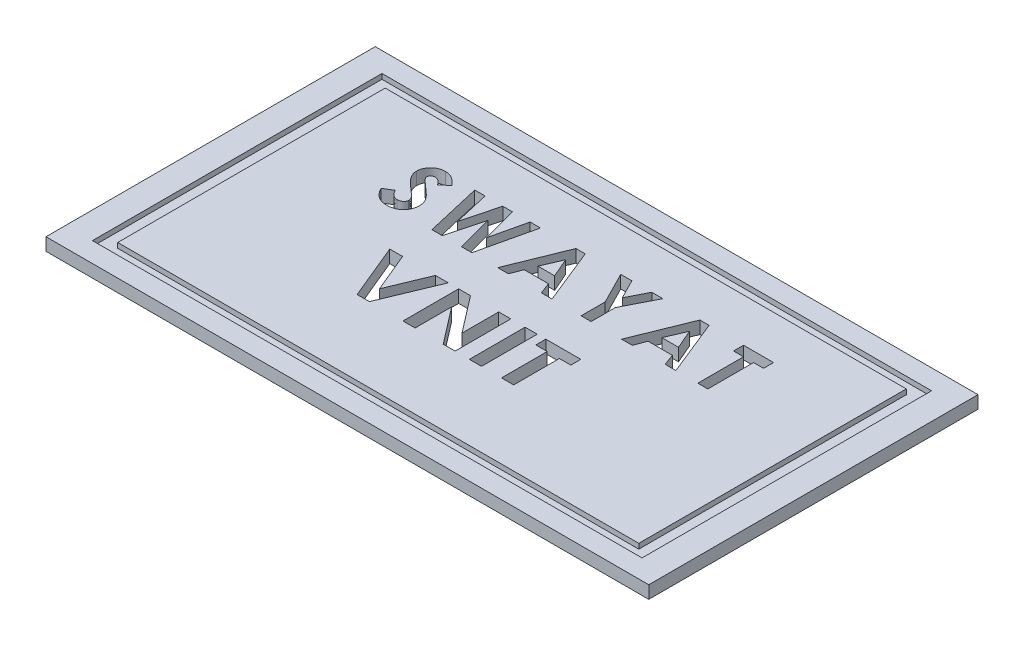
from build123d import *

# Parameters (mm, degrees)
SKETCH4_W           = 119
SKETCH4_H           = 65
BOSS_EXTRUDE2_DEPTH = 2.5
SKETCH5_W           = 2.397435898
SKETCH5_H           = 11
CUT_EXTRUDE1_DEPTH  = 2.5
SKETCH6_W           = 108.50389602
SKETCH6_H           = 57.15903792
SKETCH6_W_2         = 102.871220824
SKETCH6_H_2         = 52.803857444
CUT_EXTRUDE2_DEPTH  = 1


with BuildPart() as part:
    # Sketch4 → Boss-Extrude2 (new body)
    with BuildSketch(Plane(origin=(0, 0, 0), x_dir=(1, 0, 0), z_dir=(0, 1, 0))):
        Rectangle(SKETCH4_W, SKETCH4_H)
    extrude(amount=BOSS_EXTRUDE2_DEPTH)

    # Sketch5 → Cut-Extrude1 (cut)
    with BuildSketch(Plane(origin=(0, 2.5, 0), x_dir=(1, 0, 0), z_dir=(0, 1, 0))):
        with BuildLine():
            Line((-28.220512821, 16.333954193), (-29.696875, 14.983192975))
            add(Edge.make_bspline(
                [(-29.696875, 14.983192975), (-29.760116025, 15.072401015), (-29.881529975, 15.243668013), (-30.078329322, 15.47299856), (-30.27424002, 15.668634583), (-30.471077062, 15.829758805), (-30.670585136, 15.955392277), (-30.872417925, 16.044342163), (-31.075431182, 16.10088845), (-31.211824753, 16.107929823), (-31.27900641, 16.111398103)],
                knots=[0, 0, 0, 0, 0.000327904, 0.000629529, 0.000905322, 0.001157575, 0.001391149, 0.001610187, 0.001817564, 0.002018858, 0.002018858, 0.002018858, 0.002018858], degree=3))
            add(Edge.make_bspline(
                [(-31.27900641, 16.111398103), (-31.341671533, 16.109200441), (-31.46266142, 16.104957335), (-31.63514148, 16.06278117), (-31.788271734, 15.989991302), (-31.921902733, 15.894812427), (-32.0277582, 15.780143949), (-32.112275582, 15.659886198), (-32.15986597, 15.527148839), (-32.166129801, 15.435979466), (-32.169230769, 15.390845218)],
                knots=[0, 0, 0, 0, 0.000187766, 0.000362526, 0.000528128, 0.000693862, 0.000851302, 0.000994311, 0.001132309, 0.001267606, 0.001267606, 0.001267606, 0.001267606], degree=3))
            add(Edge.make_bspline(
                [(-32.169230769, 15.390845218), (-32.16728755, 15.345060115), (-32.163374176, 15.252855278), (-32.125576309, 15.117717608), (-32.068604132, 14.985672372), (-32.01416489, 14.905290154), (-31.986338141, 14.86420259)],
                knots=[0, 0, 0, 0, 0.000137062, 0.000276024, 0.000418096, 0.00056665, 0.00056665, 0.00056665, 0.00056665], degree=3))
            add(Edge.make_bspline(
                [(-31.986338141, 14.86420259), (-31.961040616, 14.832265656), (-31.902809053, 14.758751052), (-31.79177339, 14.642315379), (-31.652335917, 14.499671488), (-31.479130786, 14.335724484), (-31.279348218, 14.144578192), (-31.043728034, 13.933746645), (-30.779052409, 13.696700635), (-30.590927108, 13.531630378), (-30.492347756, 13.445132077)],
                knots=[0, 0, 0, 0, 0.000122172, 0.000281223, 0.000482227, 0.000720667, 0.000996565, 0.001311693, 0.001669078, 0.002062517, 0.002062517, 0.002062517, 0.002062517], degree=3))
            add(Edge.make_bspline(
                [(-30.492347756, 13.445132077), (-30.399816855, 13.365051249), (-30.224212428, 13.213074475), (-29.9743622, 12.997367846), (-29.754785462, 12.803301851), (-29.562283482, 12.633789006), (-29.399774401, 12.487050733), (-29.266575032, 12.362385625), (-29.161058569, 12.262220682), (-29.101078639, 12.201720996), (-29.075480769, 12.175901308)],
                knots=[0, 0, 0, 0, 0.000367117, 0.000696712, 0.000990236, 0.001246243, 0.00146621, 0.00164706, 0.001793557, 0.001902626, 0.001902626, 0.001902626, 0.001902626], degree=3))
            add(Edge.make_bspline(
                [(-29.075480769, 12.175901308), (-28.978367789, 12.070804265), (-28.791682538, 11.868770841), (-28.549057521, 11.555682571), (-28.349369285, 11.25004458), (-28.194886678, 10.946105793), (-28.078215201, 10.639480977), (-27.995960263, 10.322650177), (-27.946697234, 9.992302709), (-27.941227887, 9.76688089), (-27.938461538, 9.652864449)],
                knots=[0, 0, 0, 0, 0.000429122, 0.000824923, 0.001186765, 0.001522808, 0.001845705, 0.002169053, 0.002503118, 0.002845013, 0.002845013, 0.002845013, 0.002845013], degree=3))
            add(Edge.make_bspline(
                [(-27.938461538, 9.652864449), (-27.940430555, 9.54176941), (-27.944293838, 9.323796809), (-27.991611651, 9.004826376), (-28.059084074, 8.699557828), (-28.163408278, 8.411312919), (-28.290557999, 8.135360196), (-28.449958539, 7.875998124), (-28.637152617, 7.630601855), (-28.851705771, 7.403558146), (-29.089027037, 7.197531717), (-29.34357665, 7.014122124), (-29.617843723, 6.862694143), (-29.909484962, 6.738004002), (-30.218344258, 6.641965988), (-30.544053667, 6.570984945), (-30.887111383, 6.528383241), (-31.121699192, 6.523929739), (-31.241546474, 6.521654513)],
                knots=[0, 0, 0, 0, 0.000332995, 0.000653348, 0.000965503, 0.001269366, 0.001571016, 0.001875613, 0.002180592, 0.002495473, 0.00281097, 0.003122198, 0.003434889, 0.00374882, 0.004072191, 0.004403695, 0.004747798, 0.005107216, 0.005107216, 0.005107216, 0.005107216], degree=3))
            add(Edge.make_bspline(
                [(-31.241546474, 6.521654513), (-31.33562557, 6.523323539), (-31.521956134, 6.526629167), (-31.796579216, 6.553616871), (-32.061758846, 6.597172154), (-32.317196323, 6.659599885), (-32.564042437, 6.738704288), (-32.802307328, 6.835327285), (-33.030346172, 6.950966497), (-33.24988442, 7.083243923), (-33.459854845, 7.236835438), (-33.66291244, 7.408600915), (-33.857040245, 7.601182182), (-34.043170617, 7.814123794), (-34.22011264, 8.048028749), (-34.393658263, 8.299639488), (-34.556094596, 8.573625565), (-34.656438744, 8.765829014), (-34.707692308, 8.86400227)],
                knots=[0, 0, 0, 0, 0.000282189, 0.000558896, 0.000826966, 0.001087775, 0.001347005, 0.001603978, 0.001858226, 0.002113312, 0.002372036, 0.002637814, 0.002910491, 0.003191577, 0.003485539, 0.003789913, 0.004108107, 0.004440321, 0.004440321, 0.004440321, 0.004440321], degree=3))
            Line((-34.707692308, 8.86400227), (-32.971314103, 9.906269898))
            add(Edge.make_bspline(
                [(-32.971314103, 9.906269898), (-32.907203555, 9.794830426), (-32.784298156, 9.581191434), (-32.576023467, 9.294140371), (-32.36265668, 9.048328652), (-32.139264948, 8.848101013), (-31.90856463, 8.690780155), (-31.669441389, 8.578347755), (-31.421727223, 8.508752227), (-31.252995586, 8.500253006), (-31.168830128, 8.496013488)],
                knots=[0, 0, 0, 0, 0.00038546, 0.000738959, 0.001062127, 0.001360222, 0.001636464, 0.001896713, 0.00215008, 0.002402247, 0.002402247, 0.002402247, 0.002402247], degree=3))
            add(Edge.make_bspline(
                [(-31.168830128, 8.496013488), (-31.083221808, 8.499475708), (-30.917129199, 8.50619292), (-30.680053253, 8.568237782), (-30.46269305, 8.665652768), (-30.274808495, 8.804650519), (-30.115719701, 8.96507505), (-29.998303038, 9.143554676), (-29.924541099, 9.336665323), (-29.916742674, 9.470812681), (-29.912820513, 9.538281116)],
                knots=[0, 0, 0, 0, 0.000256377, 0.000497409, 0.000730108, 0.0009668, 0.001194308, 0.001404557, 0.001603924, 0.001805652, 0.001805652, 0.001805652, 0.001805652], degree=3))
            add(Edge.make_bspline(
                [(-29.912820513, 9.538281116), (-29.916442468, 9.601049515), (-29.923800123, 9.728557508), (-29.977994345, 9.918141391), (-30.062716442, 10.107639055), (-30.162948658, 10.263070165), (-30.264947489, 10.393208421), (-30.362481377, 10.505967332), (-30.481251851, 10.630546189), (-30.620957763, 10.767101702), (-30.779753233, 10.916836004), (-30.957772024, 11.079734431), (-31.157052642, 11.254362045), (-31.297904575, 11.37331665), (-31.371554487, 11.435516693)],
                knots=[0, 0, 0, 0, 0.000188127, 0.000382163, 0.000587328, 0.000809228, 0.000934848, 0.001083272, 0.001256287, 0.001451059, 0.001669286, 0.001911042, 0.002174923, 0.002464123, 0.002464123, 0.002464123, 0.002464123], degree=3))
            add(Edge.make_bspline(
                [(-31.371554487, 11.435516693), (-31.511565902, 11.553979775), (-31.780290184, 11.781346287), (-32.160031689, 12.117159467), (-32.502212786, 12.431007654), (-32.803878033, 12.726770698), (-33.068871111, 12.99898654), (-33.295397371, 13.249866222), (-33.480968321, 13.481344938), (-33.676241731, 13.755515986), (-33.861790512, 14.089612248), (-34.022157314, 14.49156878), (-34.126196527, 14.893474311), (-34.137852673, 15.163291547), (-34.143589744, 15.296093616)],
                knots=[0, 0, 0, 0, 0.000550193, 0.001055988, 0.001520686, 0.001942965, 0.002323199, 0.002660274, 0.002956572, 0.003212731, 0.003669462, 0.004098697, 0.004509151, 0.004906984, 0.004906984, 0.004906984, 0.004906984], degree=3))
            add(Edge.make_bspline(
                [(-34.143589744, 15.296093616), (-34.141203704, 15.390269715), (-34.136502949, 15.575806746), (-34.094571492, 15.848611917), (-34.031903331, 16.111845984), (-33.940891171, 16.364548551), (-33.822768376, 16.606403097), (-33.679312829, 16.838593602), (-33.508296939, 17.058983037), (-33.315573576, 17.267425299), (-33.103241772, 17.457917806), (-32.876338257, 17.626046531), (-32.636147323, 17.768050497), (-32.384138338, 17.885853097), (-32.118749706, 17.976023505), (-31.841936534, 18.039940784), (-31.553301784, 18.077956744), (-31.356978657, 18.083124572), (-31.256971154, 18.085757077)],
                knots=[0, 0, 0, 0, 0.000282361, 0.000556281, 0.000826175, 0.001093129, 0.001360202, 0.001632317, 0.001910424, 0.00219577, 0.002482889, 0.002764949, 0.003041577, 0.0033186, 0.003598031, 0.003880787, 0.004169684, 0.004469655, 0.004469655, 0.004469655, 0.004469655], degree=3))
            add(Edge.make_bspline(
                [(-31.256971154, 18.085757077), (-31.12736638, 18.081015858), (-30.869179887, 18.071570846), (-30.48744371, 17.997713939), (-30.114579773, 17.881566172), (-29.814119024, 17.74144667), (-29.575048015, 17.605712842), (-29.391822419, 17.480746232), (-29.205380513, 17.337590263), (-29.014218758, 17.175793813), (-28.821889235, 16.992308425), (-28.622923098, 16.791502113), (-28.420031501, 16.571639441), (-28.288184133, 16.414570567), (-28.220512821, 16.333954193)],
                knots=[0, 0, 0, 0, 0.000388577, 0.000774087, 0.001162264, 0.001557636, 0.001765901, 0.001986529, 0.002222317, 0.002470886, 0.002737439, 0.003019465, 0.003318885, 0.003634613, 0.003634613, 0.003634613, 0.003634613], degree=3))
        make_face()
        Polygon((-25.16025641, 17.803705795), (-23.121995192, 17.803705795), (-21.493589744, 10.781069577), (-19.627203526, 17.803705795), (-17.707932692, 17.803705795), (-15.852564103, 10.781069577), (-14.228565705, 17.803705795), (-12.185897436, 17.803705795), (-14.730969551, 6.803705795), (-16.793469551, 6.803705795), (-18.673076923, 13.914483039), (-20.563701923, 6.803705795), (-22.610777244, 6.803705795), align=None)
        Polygon((-5.174719551, 17.803705795), (-3.343589744, 17.803705795), (1.098717949, 6.803705795), (-1.01005609, 6.803705795), (-1.865024038, 9.060116052), (-6.657692308, 9.060116052), (-7.512660256, 6.803705795), (-9.619230769, 6.803705795), align=None)
        Polygon((-4.26025641, 14.853184962), (-5.90849359, 11.034475026), (-2.612019231, 11.034475026), align=None, mode=Mode.SUBTRACT)
        Polygon((3.665384615, 17.803705795), (5.862299679, 17.803705795), (7.825641026, 13.945332398), (9.788982372, 17.803705795), (11.985897436, 17.803705795), (8.812820513, 11.567728231), (8.812820513, 6.803705795), (6.838461538, 6.803705795), (6.838461538, 11.567728231), align=None)
        Polygon((19.279126603, 17.803705795), (21.11025641, 17.803705795), (25.552564103, 6.803705795), (23.443790064, 6.803705795), (22.588822115, 9.060116052), (17.796153846, 9.060116052), (16.941185897, 6.803705795), (14.834615385, 6.803705795), align=None)
        Polygon((20.193589744, 14.853184962), (18.545352564, 11.034475026), (21.841826923, 11.034475026), align=None, mode=Mode.SUBTRACT)
        Polygon((27.907692308, 17.803705795), (33.830769231, 17.803705795), (33.830769231, 15.829346821), (31.856410256, 15.829346821), (31.856410256, 6.803705795), (29.882051282, 6.803705795), (29.882051282, 15.829346821), (27.907692308, 15.829346821), align=None)
        Polygon((-23.467948718, -0.670573905), (-20.931690705, -0.670573905), (-17.685897436, -8.484275828), (-14.437900641, -0.670573905), (-11.903846154, -0.670573905), (-16.476161859, -11.670573905), (-18.900040064, -11.670573905), align=None)
        Polygon((-9.858974359, -0.670573905), (-7.525440705, -0.670573905), (-1.961538462, -7.909155635), (-1.961538462, -0.670573905), (0.435897436, -0.670573905), (0.435897436, -11.670573905), (-1.913060897, -11.670573905), (-7.461538462, -4.45402743), (-7.461538462, -11.670573905), (-9.858974359, -11.670573905), align=None)
        with Locations((4.455128205, -6.170573905)):
            Rectangle(SKETCH5_W, SKETCH5_H)
        Polygon((7.346153846, -0.670573905), (14.256410256, -0.670573905), (14.256410256, -2.644932879), (12, -2.644932879), (12, -11.670573905), (9.602564103, -11.670573905), (9.602564103, -2.644932879), (7.346153846, -2.644932879), align=None)
    extrude(amount=-CUT_EXTRUDE1_DEPTH, mode=Mode.SUBTRACT)

    # Sketch6 → Cut-Extrude2 (cut)
    with BuildSketch(Plane(origin=(0, 2.5, 0), x_dir=(1, 0, 0), z_dir=(0, 1, 0))):
        Rectangle(SKETCH6_W, SKETCH6_H)
        Rectangle(SKETCH6_W_2, SKETCH6_H_2, mode=Mode.SUBTRACT)
    extrude(amount=-CUT_EXTRUDE2_DEPTH, mode=Mode.SUBTRACT)


solid = part.part
